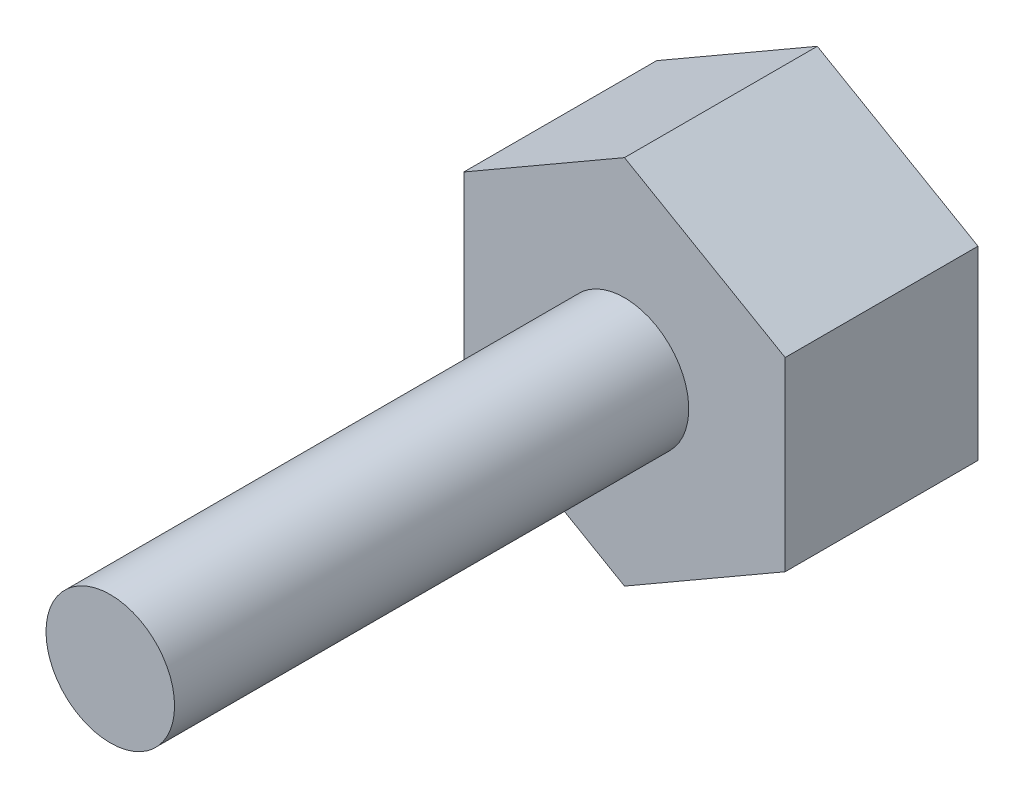
from build123d import *

# Parameters (mm, degrees)
SKETCH1_R           = 1
BOSS_EXTRUDE1_DEPTH = 8
BOSS_EXTRUDE2_DEPTH = 3


with BuildPart() as part:
    # Sketch1 → Boss-Extrude1 (new body)
    with BuildSketch(Plane.XY):
        with Locations((-63.49476159, 14.978708134)):
            Circle(SKETCH1_R)
    extrude(amount=BOSS_EXTRUDE1_DEPTH)

    # Sketch2 → Boss-Extrude2 (add)
    with BuildSketch(Plane(origin=(0, 0, 0), x_dir=(-1, 0, 0), z_dir=(0, 0, -1))):
        Polygon((63.49476159, 12.091956788), (65.99476159, 13.535332461), (65.99476159, 16.422083807), (63.49476159, 17.86545948), (60.99476159, 16.422083807), (60.99476159, 13.535332461), align=None)
    extrude(amount=BOSS_EXTRUDE2_DEPTH)


solid = part.part
